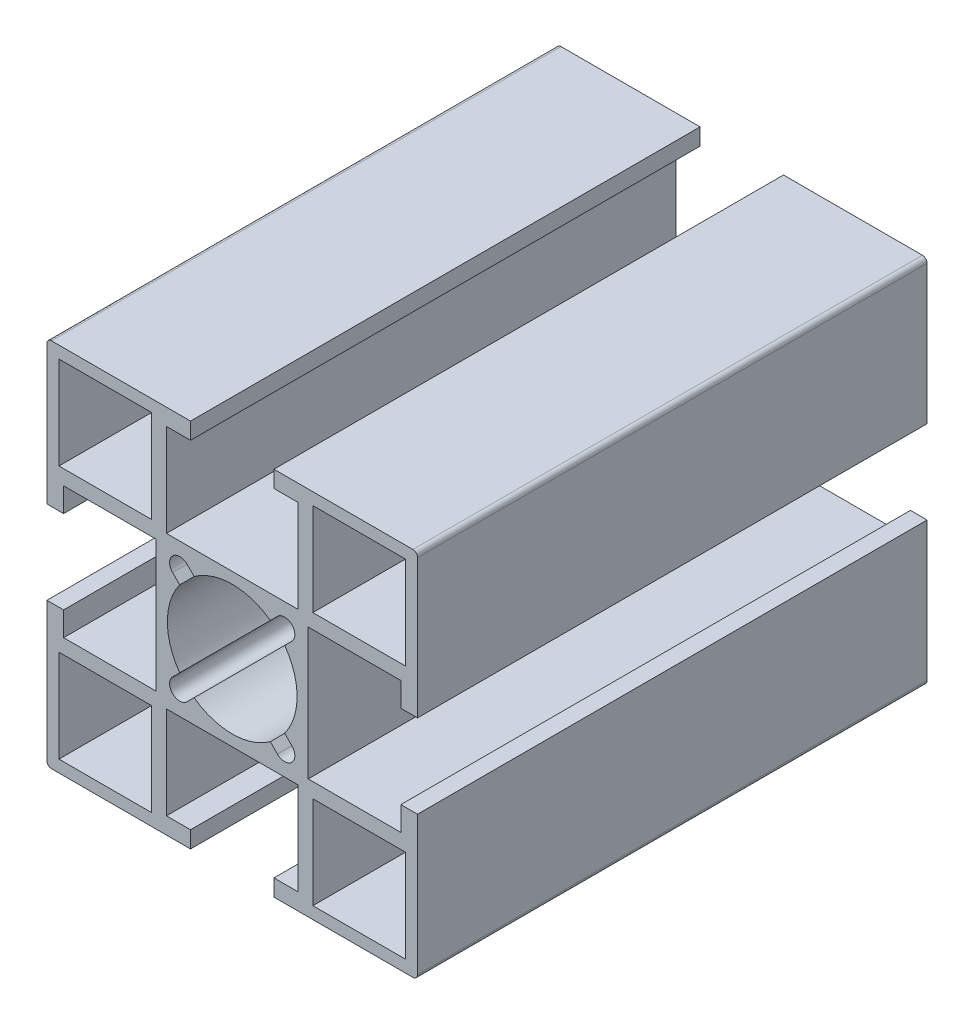
from build123d import *

# Parameters (mm, degrees)
SKETCH12_W                = 10
SKETCH12_H                = 10
F_40_X_40A_X_R0_5_1_DEPTH = 55


with BuildPart() as part:
    # Sketch12 → 铝型材 40 X 40A X R0.5(1) (new body)
    with BuildSketch(Plane.YX):
        with BuildLine():
            Line((-19.5, 20), (-4.5, 20))
            Line((-4.5, 20), (-4.5, 18.2))
            Line((-4.5, 18.2), (-7.1, 18.2))
            Line((-7.1, 18.2), (-7.1, 8.2))
            Line((-7.1, 8.2), (7.1, 8.2))
            Line((7.1, 8.2), (7.1, 18.2))
            Line((7.1, 18.2), (4.5, 18.2))
            Line((4.5, 18.2), (4.5, 20))
            Line((4.5, 20), (19.5, 20))
            ThreePointArc((19.5, 20), (19.853553391, 19.853553391), (20, 19.5))
            Line((20, 19.5), (20, 4.5))
            Line((20, 4.5), (18.2, 4.5))
            Line((18.2, 4.5), (18.2, 7.1))
            Line((18.2, 7.1), (8.2, 7.1))
            Line((8.2, 7.1), (8.2, -7.1))
            Line((8.2, -7.1), (18.2, -7.1))
            Line((18.2, -7.1), (18.2, -4.5))
            Line((18.2, -4.5), (20, -4.5))
            Line((20, -4.5), (20, -19.5))
            ThreePointArc((20, -19.5), (19.853553391, -19.853553391), (19.5, -20))
            Line((19.5, -20), (4.5, -20))
            Line((4.5, -20), (4.5, -18.2))
            Line((4.5, -18.2), (7.1, -18.2))
            Line((7.1, -18.2), (7.1, -8.2))
            Line((7.1, -8.2), (-7.1, -8.2))
            Line((-7.1, -8.2), (-7.1, -18.2))
            Line((-7.1, -18.2), (-4.5, -18.2))
            Line((-4.5, -18.2), (-4.5, -20))
            Line((-4.5, -20), (-19.5, -20))
            ThreePointArc((-19.5, -20), (-19.853553391, -19.853553391), (-20, -19.5))
            Line((-20, -19.5), (-20, -4.5))
            Line((-20, -4.5), (-18.2, -4.5))
            Line((-18.2, -4.5), (-18.2, -7.1))
            Line((-18.2, -7.1), (-8.2, -7.1))
            Line((-8.2, -7.1), (-8.2, 7.1))
            Line((-8.2, 7.1), (-18.2, 7.1))
            Line((-18.2, 7.1), (-18.2, 4.5))
            Line((-18.2, 4.5), (-20, 4.5))
            Line((-20, 4.5), (-20, 19.5))
            ThreePointArc((-20, 19.5), (-19.853553391, 19.853553391), (-19.5, 20))
        make_face()
        with BuildLine():
            Line((-4.87903679, 6.434671709), (-4.110433762, 5.66606868))
            ThreePointArc((-4.110433762, 5.66606868), (0, 7), (4.110433762, 5.66606868))
            Line((4.110433762, 5.66606868), (4.87903679, 6.434671709))
            ThreePointArc((4.87903679, 6.434671709), (6.434671709, 6.434671709), (6.434671709, 4.87903679))
            Line((6.434671709, 4.87903679), (5.66606868, 4.110433762))
            ThreePointArc((5.66606868, 4.110433762), (7, 0), (5.66606868, -4.110433762))
            Line((5.66606868, -4.110433762), (6.434671709, -4.87903679))
            ThreePointArc((6.434671709, -4.87903679), (6.434671709, -6.434671709), (4.87903679, -6.434671709))
            Line((4.87903679, -6.434671709), (4.110433762, -5.66606868))
            ThreePointArc((4.110433762, -5.66606868), (0, -7), (-4.110433762, -5.66606868))
            Line((-4.110433762, -5.66606868), (-4.87903679, -6.434671709))
            ThreePointArc((-4.87903679, -6.434671709), (-6.434671709, -6.434671709), (-6.434671709, -4.87903679))
            Line((-6.434671709, -4.87903679), (-5.66606868, -4.110433762))
            ThreePointArc((-5.66606868, -4.110433762), (-7, 0), (-5.66606868, 4.110433762))
            Line((-5.66606868, 4.110433762), (-6.434671709, 4.87903679))
            ThreePointArc((-6.434671709, 4.87903679), (-6.434671709, 6.434671709), (-4.87903679, 6.434671709))
        make_face(mode=Mode.SUBTRACT)
        with Locations((-13.7, 13.7)):
            Rectangle(SKETCH12_W, SKETCH12_H, mode=Mode.SUBTRACT)
        with Locations((13.7, 13.7)):
            Rectangle(SKETCH12_W, SKETCH12_H, mode=Mode.SUBTRACT)
        with Locations((13.7, -13.7)):
            Rectangle(SKETCH12_W, SKETCH12_H, mode=Mode.SUBTRACT)
        with Locations((-13.7, -13.7)):
            Rectangle(SKETCH12_W, SKETCH12_H, mode=Mode.SUBTRACT)
    extrude(amount=F_40_X_40A_X_R0_5_1_DEPTH)


solid = part.part
